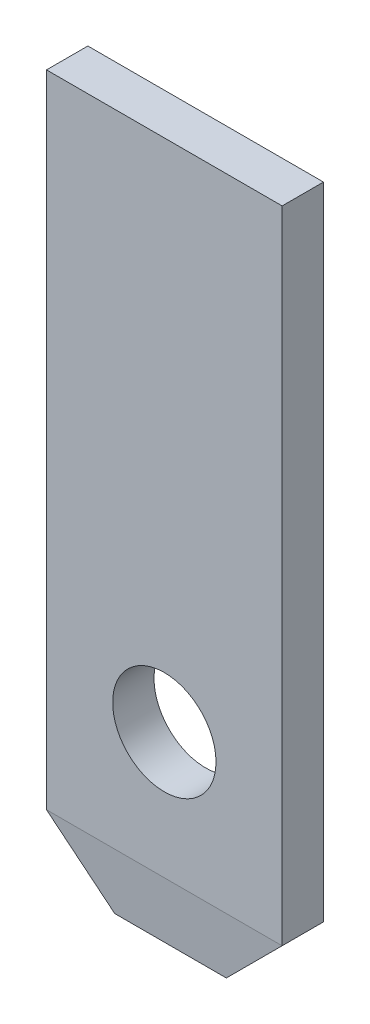
from build123d import *

# Parameters (mm, degrees)
SKETCH1_W      = 2.85
SKETCH1_H      = 8.5
SKETCH1_R      = 0.625
EXTRUDE1_DEPTH = 0.25
CHAMFER1_SIZE  = 0.075
CHAMFER1_SIZE2 = 0.75
CHAMFER2_SIZE  = 0.75


with BuildPart() as part:
    # Sketch1 → Extrude1 (new body, symmetric)
    with BuildSketch(Plane.XY):
        with Locations((0, 4.25)):
            Rectangle(SKETCH1_W, SKETCH1_H)
        with Locations((0, 2.275)):
            Circle(SKETCH1_R, mode=Mode.SUBTRACT)
    extrude(amount=EXTRUDE1_DEPTH, both=True)

    # Chamfer1
    chamfer1_edges = [part.edges().sort_by_distance(p)[0] for p in [
        (0, 0, 0.25),
        (0, 0, -0.25),
    ]]
    chamfer1_side = [part.faces().sort_by_distance(p)[0] for p in [
        (0, 0, 0),
    ]]
    chamfer(chamfer1_edges, length=CHAMFER1_SIZE, length2=CHAMFER1_SIZE2, reference=chamfer1_side[0])

    # Chamfer2
    chamfer2_edges = [part.edges().sort_by_distance(p)[0] for p in [
        (1.425, 0, 0),
        (-1.425, 0, 0),
    ]]
    chamfer(chamfer2_edges, length=CHAMFER2_SIZE)


solid = part.part
